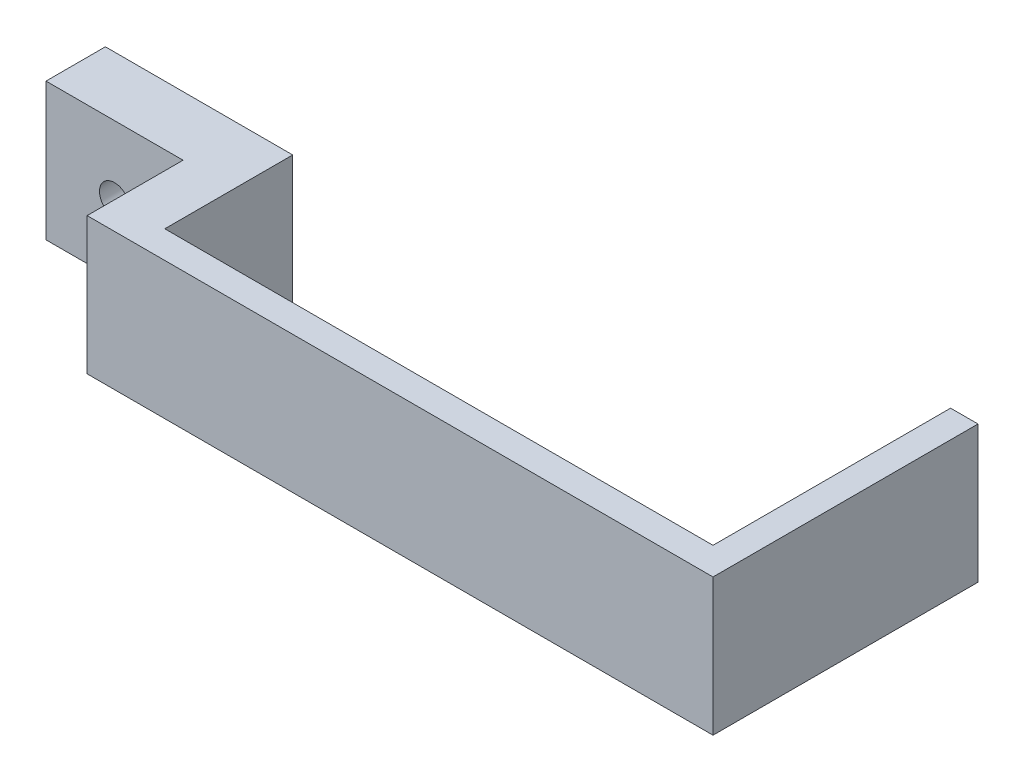
from build123d import *

# Parameters (mm, degrees)
RESSALTO_EXTRUS_O1_DEPTH                             = 6
ESBO_O2_W                                            = 11
ESBO_O2_H                                            = 30.1
RESSALTO_EXTRUS_O2_DEPTH                             = 28
ESBO_O3_W                                            = 13
ESBO_O3_H                                            = 30.1
RESSALTO_EXTRUS_O3_DEPTH                             = 30
REBAIXO_PARA_PARAFUSO_DE_M_QUINA_COM_CAB_D           = 6.6
REBAIXO_PARA_PARAFUSO_DE_M_QUINA_COM_CAB_CBORE_D     = 13
REBAIXO_PARA_PARAFUSO_DE_M_QUINA_COM_CAB_CBORE_DEPTH = 4.6
ESBO_O7_W                                            = 6
ESBO_O7_H                                            = 30
RESSALTO_EXTRUS_O4_DEPTH                             = 52


with BuildPart() as part:
    # Esboço1 → Ressalto-extrusão1 (new body)
    with BuildSketch(Plane.XY):
        Polygon((59.5, -82.5), (-70.5, -82.5), (-70.5, -52.5), (59.5, -52.5), (66.5, -52.5), (66.5, -82.5), align=None)
    extrude(amount=RESSALTO_EXTRUS_O1_DEPTH)

    # Esboço2 → Ressalto-extrusão2 (add)
    with BuildSketch(Plane(origin=(0, 0, 0), x_dir=(-1, 0, 0), z_dir=(0, 0, -1))):
        with Locations((65, -67.55)):
            Rectangle(ESBO_O2_W, ESBO_O2_H)
    extrude(amount=RESSALTO_EXTRUS_O2_DEPTH)

    # Esboço3 → Ressalto-extrusão3 (add)
    with BuildSketch(Plane.ZY.offset(70.5)):
        with Locations((-21.5, -67.55)):
            Rectangle(ESBO_O3_W, ESBO_O3_H)
    extrude(amount=RESSALTO_EXTRUS_O3_DEPTH)

    # Rebaixo para parafuso de máquina com cabeça panela de M61 (through all)
    with Locations(Plane(origin=(-85.492891977, -67.55, -28), x_dir=(-1, 0, 0), z_dir=(0, 0, -1))):
        with Locations((0, 0)):
            CounterBoreHole(REBAIXO_PARA_PARAFUSO_DE_M_QUINA_COM_CAB_D / 2, REBAIXO_PARA_PARAFUSO_DE_M_QUINA_COM_CAB_CBORE_D / 2, REBAIXO_PARA_PARAFUSO_DE_M_QUINA_COM_CAB_CBORE_DEPTH)

    # Esboço7 → Ressalto-extrusão4 (add)
    with BuildSketch(Plane(origin=(0, 0, 0), x_dir=(-1, 0, 0), z_dir=(0, 0, -1))):
        with Locations((-63.5, -67.5)):
            Rectangle(ESBO_O7_W, ESBO_O7_H)
    extrude(amount=RESSALTO_EXTRUS_O4_DEPTH)


solid = part.part
